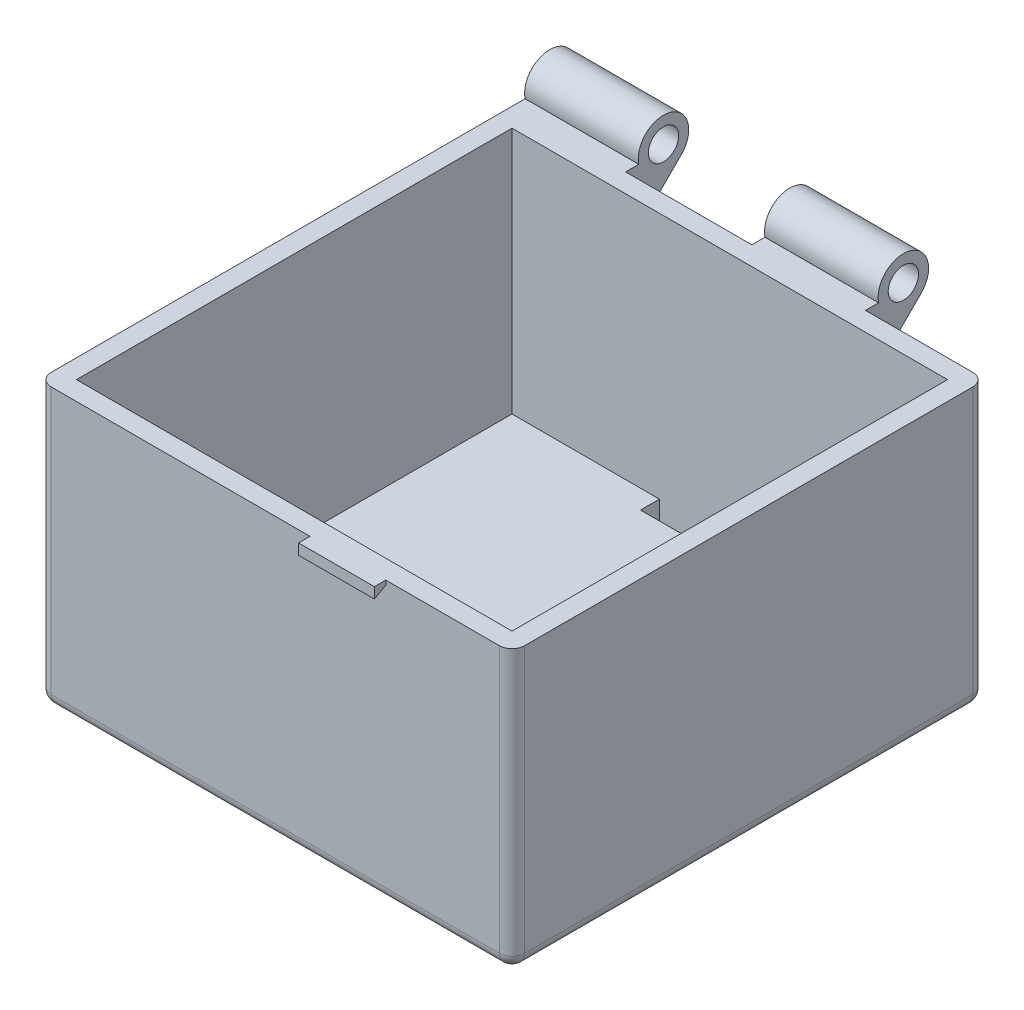
from build123d import *

# Parameters (mm, degrees)
SKETCH1_W                 = 95.25
SKETCH1_H                 = 95.25
BOSS_EXTRUDE1_DEPTH       = 57.15
SHELL1_T                  = -3.81
SHELL1_THICKNESS_2_FACE_W = 87.63
SHELL1_THICKNESS_2_FACE_H = 87.63
SHELL1_THICKNESS_2_DEPTH  = 2.54
SKETCH2_R                 = 3.048
BOSS_EXTRUDE2_DEPTH       = 22.86
BOSS_EXTRUDE3_START       = -46.99
SKETCH5_R                 = 3.048
BOSS_EXTRUDE3_DEPTH       = 22.86
SKETCH2_3_W               = 95.25
SKETCH2_3_H               = 1.000000032
CUT_EXTRUDE1_DEPTH        = 129.779816062
SKETCH6_W                 = 28.300000042
SKETCH6_H                 = 28.702
CUT_EXTRUDE2_DEPTH        = 4.318
SKETCH7_W                 = 28.300000042
SKETCH7_H                 = 3.81
CUT_EXTRUDE3_DEPTH        = 3.81
BOSS_EXTRUDE4_DEPTH       = 0.762
FILLET1_R                 = 2.54
BOSS_EXTRUDE7_START       = -47.625
BOSS_EXTRUDE7_DEPTH       = 22.225
SKETCH17_OUTSIDE_W        = 128.934
SKETCH17_OUTSIDE_H        = 95.914
SKETCH17_OUTSIDE_W_2      = 15.24
SKETCH17_OUTSIDE_H_2      = 2.159
CUT_EXTRUDE18_DEPTH       = 2.286


with BuildPart() as part:
    # Sketch1 → Boss-Extrude1 (new body)
    with BuildSketch(Plane(origin=(0, 0, 0), x_dir=(1, 0, 0), z_dir=(0, 1, 0))):
        Rectangle(SKETCH1_W, SKETCH1_H)
    extrude(amount=BOSS_EXTRUDE1_DEPTH)

    # Shell1
    shell1_openings = [part.faces().sort_by_distance(p)[0] for p in [
        (0, 57.15, 0),
    ]]
    offset(amount=SHELL1_T, openings=shell1_openings, kind=Kind.INTERSECTION)

    # Shell1 thickness 2 face (on inner face of the shell) → Shell1 thickness 2 (add)
    with BuildSketch(Plane(origin=(0, 3.81, 0), x_dir=(0, 0, -1), z_dir=(0, -1, 0))):
        Rectangle(SHELL1_THICKNESS_2_FACE_W, SHELL1_THICKNESS_2_FACE_H)
    extrude(amount=-SHELL1_THICKNESS_2_DEPTH)

    # Sketch2 → Boss-Extrude2 (add)
    with BuildSketch(Plane.ZY.offset(47.625)):
        with BuildLine():
            ThreePointArc((-50.165, 57.15), (-57.189031836, 61.843308025), (-58.837102448, 53.557897552))
            Line((-58.837102448, 53.557897552), (-47.625, 42.345795103))
            Line((-47.625, 42.345795103), (-47.625, 56.149999968))
            Line((-47.625, 56.149999968), (-50.264397633, 56.149999968))
            ThreePointArc((-50.264397633, 56.149999968), (-50.189910484, 56.647536083), (-50.165, 57.15))
        make_face()
        with Locations((-55.245, 57.15)):
            Circle(SKETCH2_R, mode=Mode.SUBTRACT)
    extrude(amount=-BOSS_EXTRUDE2_DEPTH)

    # Sketch5 → Boss-Extrude3 (add)
    with BuildSketch(Plane(origin=(47.625, 0, 0), x_dir=(0, 0, -1), z_dir=(1, 0, 0)).offset(BOSS_EXTRUDE3_START)):
        with BuildLine():
            Line((47.625, 56.149999968), (47.625, 42.345795103))
            Line((47.625, 42.345795103), (58.837102448, 53.557897552))
            ThreePointArc((58.837102448, 53.557897552), (56.715282878, 62.012578355), (50.264397633, 56.149999968))
            Line((50.264397633, 56.149999968), (47.625, 56.149999968))
        make_face()
        with Locations((55.245, 57.15)):
            Circle(SKETCH5_R, mode=Mode.SUBTRACT)
    extrude(amount=BOSS_EXTRUDE3_DEPTH)

    # Sketch2_3 → Cut-Extrude1 (cut, through all)
    with BuildSketch(Plane.ZY.offset(47.625)):
        with Locations((0, 56.649999984)):
            Rectangle(SKETCH2_3_W, SKETCH2_3_H)
    extrude(amount=-CUT_EXTRUDE1_DEPTH, mode=Mode.SUBTRACT)

    # Sketch6 → Cut-Extrude2 (cut)
    with BuildSketch(Plane.XZ):
        with Locations((0, -29.464)):
            Rectangle(SKETCH6_W, SKETCH6_H)
    extrude(amount=-CUT_EXTRUDE2_DEPTH, mode=Mode.SUBTRACT)

    # Sketch7 → Cut-Extrude3 (cut)
    with BuildSketch(Plane(origin=(0, 4.318, 0), x_dir=(-1, 0, 0), z_dir=(0, -1, 0))):
        with Locations((0, 41.91)):
            Rectangle(SKETCH7_W, SKETCH7_H)
    extrude(amount=-CUT_EXTRUDE3_DEPTH, mode=Mode.SUBTRACT)

    # Sketch8 → Boss-Extrude4 (add)
    with BuildSketch(Plane.XZ):
        Polygon((-11.610000021, -15.113), (-14.150000021, -15.113), (-14.150000021, -20.595), (-14.150000021, -28.57736709), (-11.610000021, -28.57736709), (-11.610000021, -20.193), (11.610000021, -20.193), (11.610000021, -28.57736709), (14.150000021, -28.57736709), (14.150000021, -20.595), (14.150000021, -15.113), (11.610000021, -15.113), align=None)
    extrude(amount=-BOSS_EXTRUDE4_DEPTH)

    # Fillet1
    fillet1_edges = [part.edges().sort_by_distance(p)[0] for p in [
        (-47.625, 0, 0),
        (47.625, 0, 0),
        (0, 0, -47.625),
        (47.625, 28.074999984, -47.625),
        (-47.625, 21.172897552, -47.625),
        (47.625, 28.074999984, 47.625),
        (-47.625, 28.074999984, 47.625),
        (0, 0, 47.625),
    ]]
    fillet(fillet1_edges, radius=FILLET1_R)

    # Sketch13 → Boss-Extrude7 (add, symmetric)
    with BuildSketch(Plane.ZY.offset(47.625).offset(BOSS_EXTRUDE7_START)):
        Polygon((47.625, 55.260999968), (47.625, 59.070999968), (49.911, 60.340999968), (49.911, 53.990999968), align=None)
    extrude(amount=BOSS_EXTRUDE7_DEPTH, both=True)

    # Sketch17 outside → Cut-Extrude18 (cut)
    with BuildSketch(Plane.XY.offset(49.911)):
        with Locations((0, 31.115)):
            Rectangle(SKETCH17_OUTSIDE_W, SKETCH17_OUTSIDE_H)
        with Locations((14.605, 55.070499968)):
            Rectangle(SKETCH17_OUTSIDE_W_2, SKETCH17_OUTSIDE_H_2, mode=Mode.SUBTRACT)
    extrude(amount=-CUT_EXTRUDE18_DEPTH, mode=Mode.SUBTRACT)


solid = part.part
